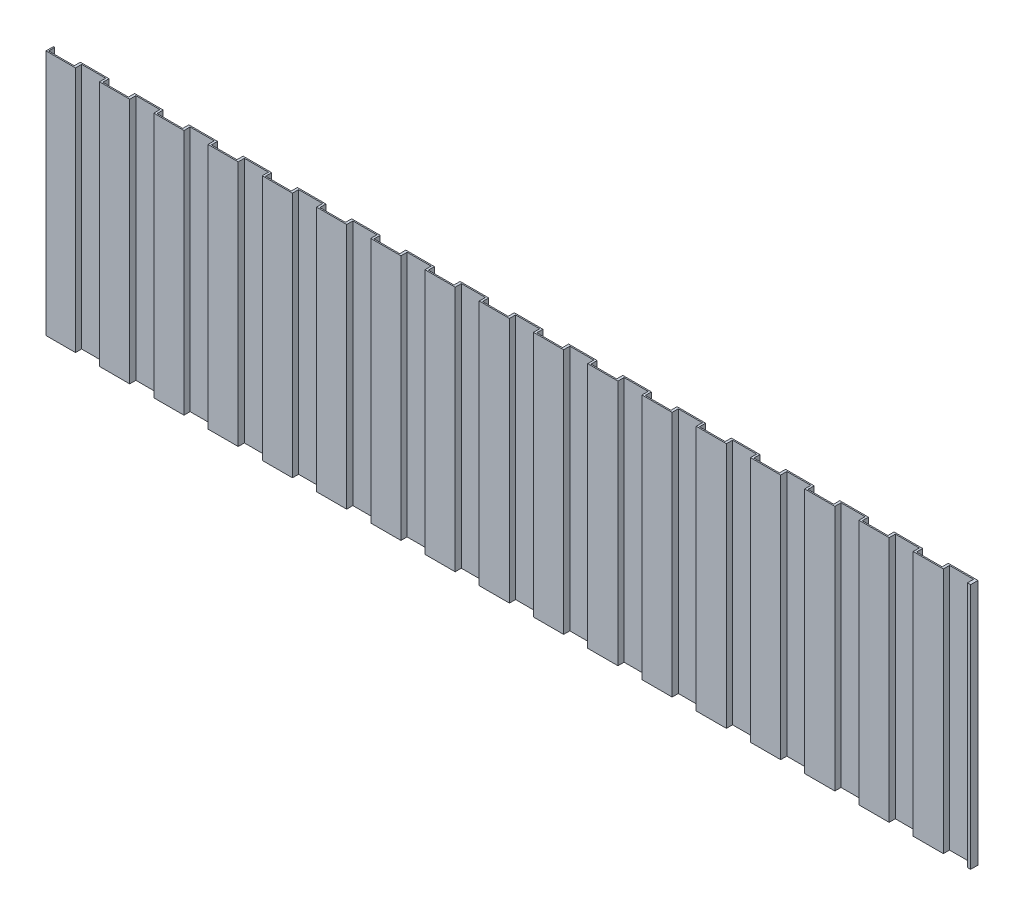
from build123d import *

# Parameters (mm, degrees)
SKETCH1_W           = 7500
SKETCH1_H           = 4000
BOSS_EXTRUDE1_DEPTH = 60
SKETCH2_W           = 208.04993412
SKETCH2_H           = 50
SKETCH2_W_2         = 195.302892205
CUT_EXTRUDE1_DEPTH  = 5107
SKETCH3_W           = 8856.494382811
SKETCH3_H           = 2648.009884852
CUT_EXTRUDE2_DEPTH  = 887


with BuildPart() as part:
    # Sketch1 → Boss-Extrude1 (new body)
    with BuildSketch(Plane.XY):
        Rectangle(SKETCH1_W, SKETCH1_H)
    extrude(amount=BOSS_EXTRUDE1_DEPTH)

    # Sketch2 → Cut-Extrude1 (cut)
    with BuildSketch(Plane(origin=(0, -2000, 0), x_dir=(-1, 0, 0), z_dir=(0, -1, 0))):
        with Locations((3635.051095731, -25)):
            Rectangle(SKETCH2_W, SKETCH2_H)
        with Locations((3413.343616701, -35)):
            Rectangle(SKETCH2_W_2, SKETCH2_H)
        with Locations((3195.051095731, -25)):
            Rectangle(SKETCH2_W, SKETCH2_H)
        with Locations((2973.343616701, -35)):
            Rectangle(SKETCH2_W_2, SKETCH2_H)
        with Locations((2755.051095731, -25)):
            Rectangle(SKETCH2_W, SKETCH2_H)
        with Locations((2533.343616701, -35)):
            Rectangle(SKETCH2_W_2, SKETCH2_H)
        with Locations((2315.051095731, -25)):
            Rectangle(SKETCH2_W, SKETCH2_H)
        with Locations((2093.343616701, -35)):
            Rectangle(SKETCH2_W_2, SKETCH2_H)
        with Locations((1875.051095731, -25)):
            Rectangle(SKETCH2_W, SKETCH2_H)
        with Locations((1653.343616701, -35)):
            Rectangle(SKETCH2_W_2, SKETCH2_H)
        with Locations((1435.051095731, -25)):
            Rectangle(SKETCH2_W, SKETCH2_H)
        with Locations((1213.343616701, -35)):
            Rectangle(SKETCH2_W_2, SKETCH2_H)
        with Locations((995.051095731, -25)):
            Rectangle(SKETCH2_W, SKETCH2_H)
        with Locations((773.343616701, -35)):
            Rectangle(SKETCH2_W_2, SKETCH2_H)
        with Locations((555.051095731, -25)):
            Rectangle(SKETCH2_W, SKETCH2_H)
        with Locations((333.343616701, -35)):
            Rectangle(SKETCH2_W_2, SKETCH2_H)
        with Locations((115.051095731, -25)):
            Rectangle(SKETCH2_W, SKETCH2_H)
        with Locations((-106.6563833, -35)):
            Rectangle(SKETCH2_W_2, SKETCH2_H)
        with Locations((-324.948904269, -25)):
            Rectangle(SKETCH2_W, SKETCH2_H)
        with Locations((-546.6563833, -35)):
            Rectangle(SKETCH2_W_2, SKETCH2_H)
        with Locations((-764.948904269, -25)):
            Rectangle(SKETCH2_W, SKETCH2_H)
        with Locations((-986.6563833, -35)):
            Rectangle(SKETCH2_W_2, SKETCH2_H)
        with Locations((-1204.948904269, -25)):
            Rectangle(SKETCH2_W, SKETCH2_H)
        with Locations((-1426.6563833, -35)):
            Rectangle(SKETCH2_W_2, SKETCH2_H)
        with Locations((-1644.948904269, -25)):
            Rectangle(SKETCH2_W, SKETCH2_H)
        with Locations((-1866.6563833, -35)):
            Rectangle(SKETCH2_W_2, SKETCH2_H)
        with Locations((-2084.948904269, -25)):
            Rectangle(SKETCH2_W, SKETCH2_H)
        with Locations((-2306.6563833, -35)):
            Rectangle(SKETCH2_W_2, SKETCH2_H)
        with Locations((-2524.948904269, -25)):
            Rectangle(SKETCH2_W, SKETCH2_H)
        with Locations((-2746.6563833, -35)):
            Rectangle(SKETCH2_W_2, SKETCH2_H)
        with Locations((-2964.948904269, -25)):
            Rectangle(SKETCH2_W, SKETCH2_H)
        with Locations((-3186.6563833, -35)):
            Rectangle(SKETCH2_W_2, SKETCH2_H)
        with Locations((-3404.948904269, -25)):
            Rectangle(SKETCH2_W, SKETCH2_H)
        with Locations((-3626.6563833, -35)):
            Rectangle(SKETCH2_W_2, SKETCH2_H)
    extrude(amount=-CUT_EXTRUDE1_DEPTH, mode=Mode.SUBTRACT)

    # Sketch3 → Cut-Extrude2 (cut)
    with BuildSketch(Plane.XY.offset(60)):
        with Locations((480.44061202, -1324.004942426)):
            Rectangle(SKETCH3_W, SKETCH3_H)
    extrude(amount=-CUT_EXTRUDE2_DEPTH, mode=Mode.SUBTRACT)


solid = part.part
